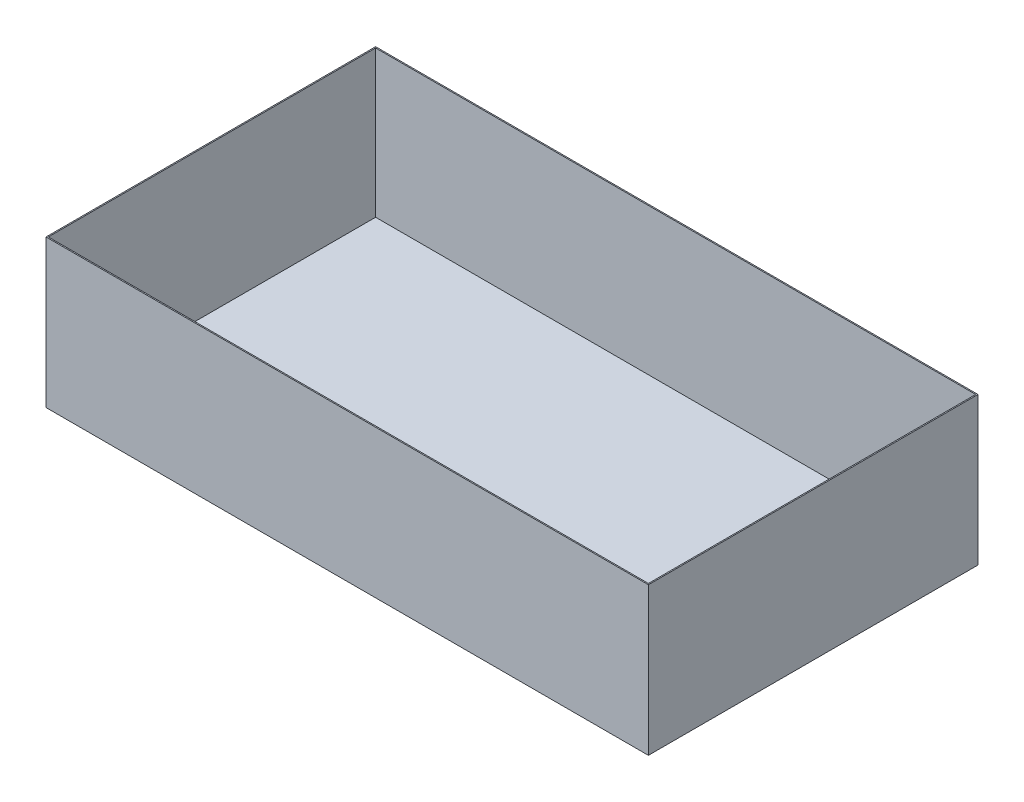
from build123d import *

# Parameters (mm, degrees)
SKETCH1_W           = 530
SKETCH1_H           = 290
BOSS_EXTRUDE1_DEPTH = 130
SHELL2_T            = -1


with BuildPart() as part:
    # Sketch1 → Boss-Extrude1 (new body)
    with BuildSketch(Plane(origin=(0, 0, 0), x_dir=(1, 0, 0), z_dir=(0, 1, 0))):
        with Locations((40.023847377, -54.419713831)):
            Rectangle(SKETCH1_W, SKETCH1_H)
    extrude(amount=BOSS_EXTRUDE1_DEPTH)

    # Shell2
    shell2_openings = [part.faces().sort_by_distance(p)[0] for p in [
        (40.023847377, 130, 54.419713831),
    ]]
    offset(amount=SHELL2_T, openings=shell2_openings, kind=Kind.INTERSECTION)


solid = part.part
